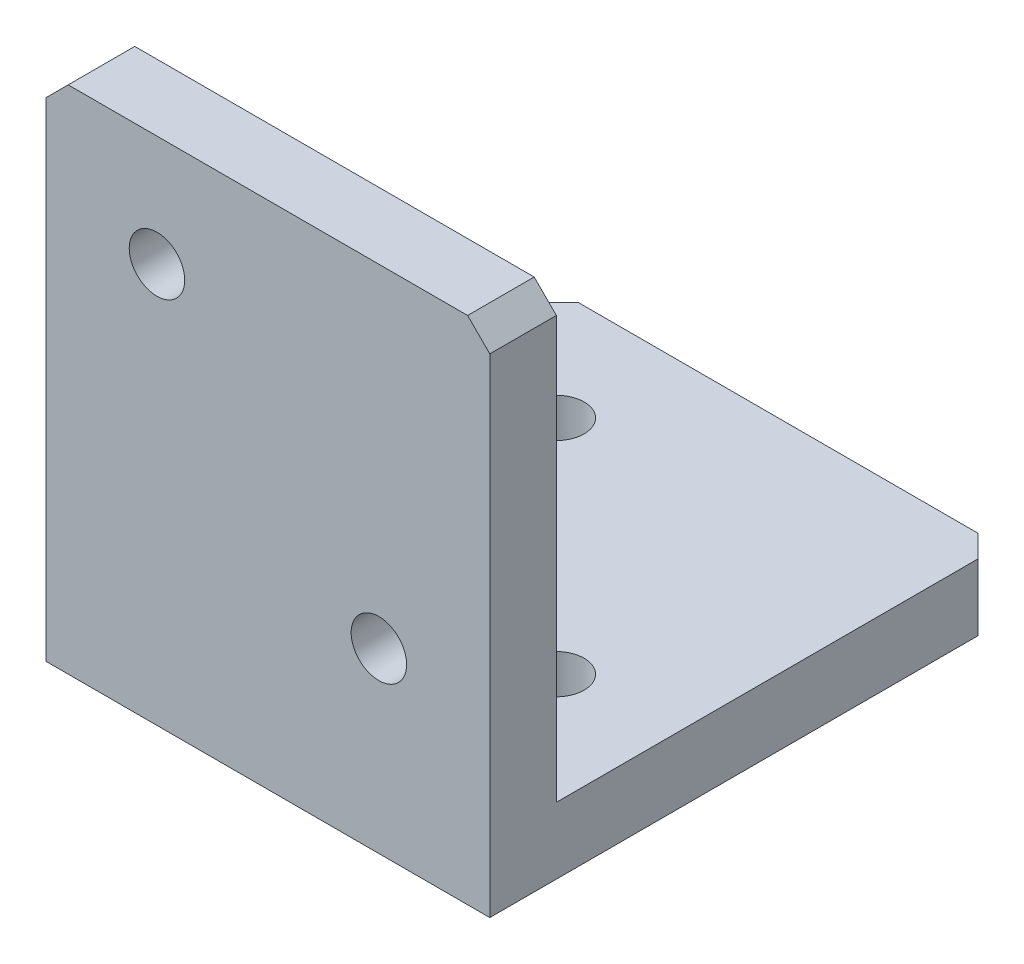
from build123d import *

# Parameters (mm, degrees)
SKETCH_1_W             = 20
SKETCH_1_H             = 20
EXTRUDE_1_DEPTH        = 3
SKETCH_2_W             = 20
SKETCH_2_H             = 3
EXTRUDE_2_DEPTH        = 23
HOLE_WIZARD_M3_1_D     = 2.5
HOLE_WIZARD_M3_1_DEPTH = 7.5
HOLE_WIZARD_M3_1_TIP   = 0.751075774
HOLE_WIZARD_M3_2_D     = 2.5
HOLE_WIZARD_M3_2_DEPTH = 7.5
HOLE_WIZARD_M3_2_TIP   = 0.751075774
CHAMFER_1_SIZE         = 1


with BuildPart() as part:
    # 草图1 → 凸台-拉伸1 (new body)
    with BuildSketch(Plane.XY):
        Rectangle(SKETCH_1_W, SKETCH_1_H)
    extrude(amount=EXTRUDE_1_DEPTH)

    # 草图2 → 凸台-拉伸2 (add)
    with BuildSketch(Plane.XY.offset(3)):
        with Locations((0, -11.5)):
            Rectangle(SKETCH_2_W, SKETCH_2_H)
    extrude(amount=-EXTRUDE_2_DEPTH)

    # M3 螺纹孔1
    with Locations(Plane(origin=(0, 0, 0), x_dir=(-1, 0, 0), z_dir=(0, 0, -1))):
        with Locations((5, 5), (-5, -5)):
            Hole(HOLE_WIZARD_M3_1_D / 2, depth=HOLE_WIZARD_M3_1_DEPTH)
            with Locations((0, 0, -(HOLE_WIZARD_M3_1_DEPTH + HOLE_WIZARD_M3_1_TIP / 2))):  # 118° drill point
                Cone(0, HOLE_WIZARD_M3_1_D / 2, HOLE_WIZARD_M3_1_TIP, mode=Mode.SUBTRACT)

    # M3 螺纹孔2
    with Locations(Plane(origin=(0, -10, 0), x_dir=(1, 0, 0), z_dir=(0, 1, 0))):
        with Locations((-5, 15), (5, 5)):
            Hole(HOLE_WIZARD_M3_2_D / 2, depth=HOLE_WIZARD_M3_2_DEPTH)
            with Locations((0, 0, -(HOLE_WIZARD_M3_2_DEPTH + HOLE_WIZARD_M3_2_TIP / 2))):  # 118° drill point
                Cone(0, HOLE_WIZARD_M3_2_D / 2, HOLE_WIZARD_M3_2_TIP, mode=Mode.SUBTRACT)

    # 倒角1
    chamfer_1_edges = [part.edges().sort_by_distance(p)[0] for p in [
        (-10, -11.5, -20),
        (10, -11.5, -20),
        (-10, 10, 1.5),
        (10, 10, 1.5),
    ]]
    chamfer(chamfer_1_edges, length=CHAMFER_1_SIZE)


solid = part.part
